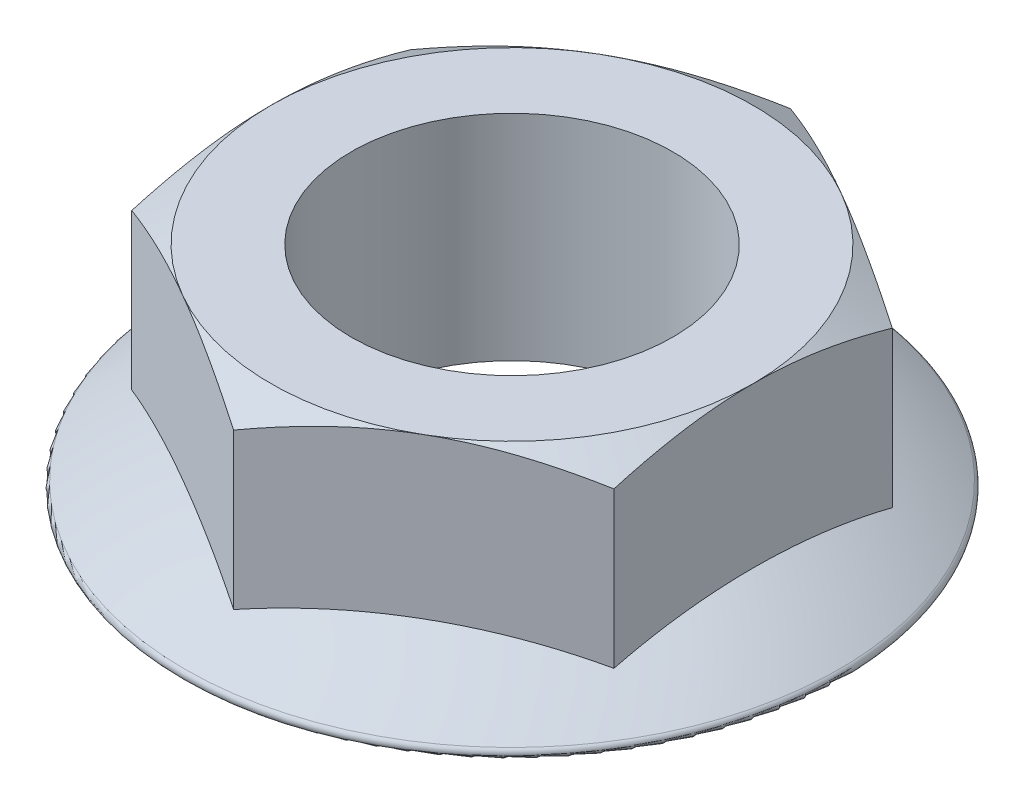
from build123d import *

# Parameters (mm, degrees)
BOSS_EXTRUDE1_DEPTH       = 20
FILLET1_R                 = 0.5
F_1_5MM_DOWEL_HOLE1_D     = 30
F_1_5MM_DOWEL_HOLE1_DEPTH = 20


with BuildPart() as part:
    # Sketch1 → Boss-Extrude1 (new body)
    with BuildSketch(Plane(origin=(0, 0, 0), x_dir=(1, 0, 0), z_dir=(0, 1, 0))):
        Polygon((0, 25.980762114), (-22.5, 12.990381057), (-22.5, -12.990381057), (0, -25.980762114), (22.5, -12.990381057), (22.5, 12.990381057), align=None)
    extrude(amount=BOSS_EXTRUDE1_DEPTH)

    # Sketch3 → Revolve1 (revolve)
    with BuildSketch(Plane(origin=(0, 0, 0), x_dir=(0, 0, -1), z_dir=(1, 0, 0))):
        with BuildLine():
            Line((0, 9.682153322), (0, 0))
            Line((0, 0), (31.95, 0))
            ThreePointArc((31.95, 0), (16.692412894, 7.208457265), (0, 9.682153322))
        make_face()
    revolve(axis=Axis((0, 0, 0), (0, 1, 0)))

    # Fillet1
    fillet1_edges = [part.edges().sort_by_distance(p)[0] for p in [
        (0, 0, 31.95),
    ]]
    fillet(fillet1_edges, radius=FILLET1_R)

    # Ø1.5mm Dowel Hole1
    with Locations(Plane(origin=(0, 20, 0), x_dir=(1, 0, 0), z_dir=(0, 1, 0))):
        with Locations((0, 0)):
            Hole(F_1_5MM_DOWEL_HOLE1_D / 2, depth=F_1_5MM_DOWEL_HOLE1_DEPTH)

    # Sketch6 → Cut-Revolve1 (revolve, cut)
    with BuildSketch(Plane.XY):
        Polygon((22.5, 20), (28.5, 20), (28.5, 16.535898385), align=None)
    revolve(axis=Axis((0, 0, 0), (0, 1, 0)), mode=Mode.SUBTRACT)


solid = part.part
